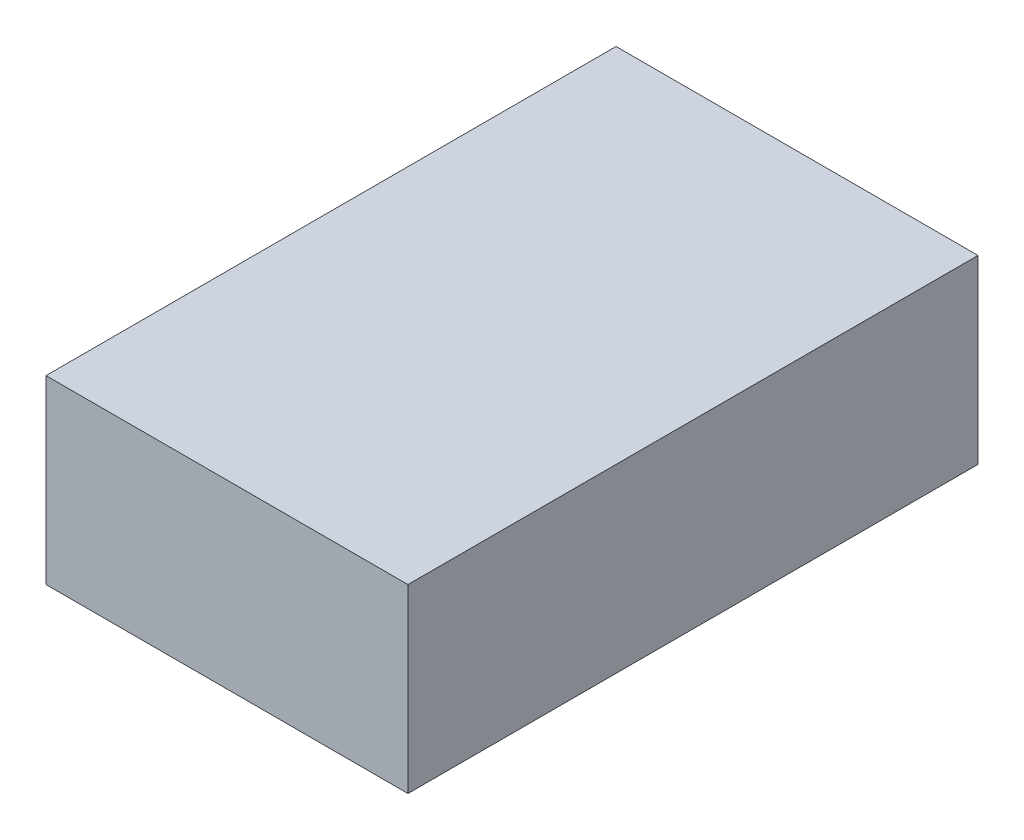
from build123d import *

# Parameters (mm, degrees)
SKETCH_1_W      = 40
SKETCH_1_H      = 63
EXTRUDE_1_DEPTH = 20


with BuildPart() as part:
    # 草图1 → 凸台-拉伸1 (new body)
    with BuildSketch(Plane(origin=(0, 0, 0), x_dir=(1, 0, 0), z_dir=(0, 1, 0))):
        with Locations((20, -31.5)):
            Rectangle(SKETCH_1_W, SKETCH_1_H)
    extrude(amount=EXTRUDE_1_DEPTH)


solid = part.part
